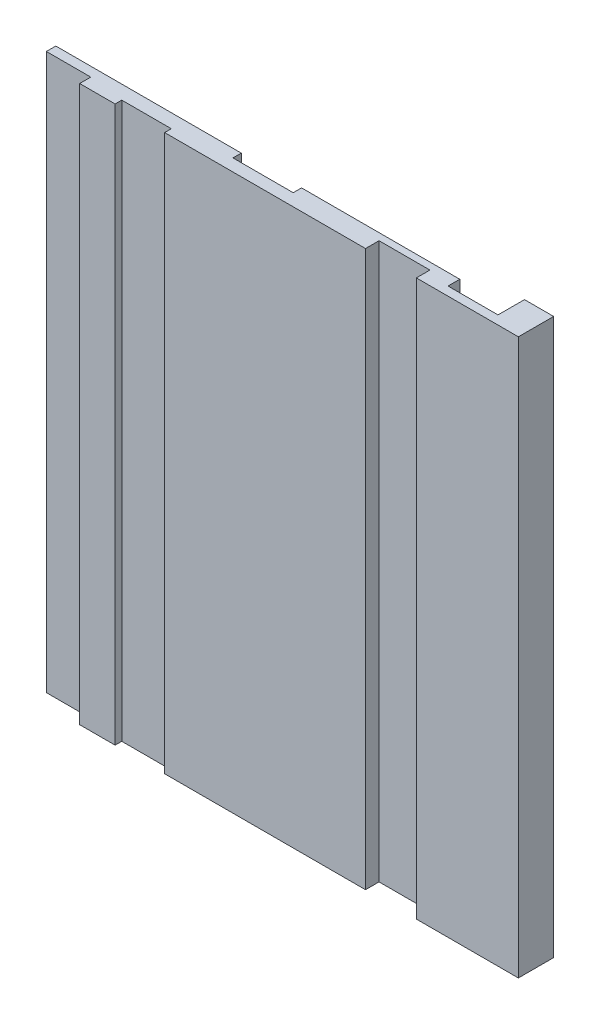
from build123d import *

# Parameters (mm, degrees)
BOSS_EXTRUDE1_DEPTH = 100


with BuildPart() as part:
    # Sketch1 → Boss-Extrude1 (new body)
    with BuildSketch(Plane(origin=(0, 0, 0), x_dir=(1, 0, 0), z_dir=(0, 1, 0))):
        Polygon((-87, 3.7), (-53.6, 3.7), (-53.6, 2.2), (-42.75, 2.2), (-42.75, 3.7), (-14.25, 3.7), (-14.25, 1.58), (-5.25, 1.58), (-5.25, 3.7), (-5.25, 6.35), (0, 6.35), (0, 0), (-18.37, 0), (-18.37, 2.44), (-27.53, 2.44), (-27.53, 0), (-63.7, 0), (-63.7, 1.2), (-72.62, 1.2), (-72.62, 0), (-79, 0), (-79, 2), (-87, 2), align=None)
    extrude(amount=BOSS_EXTRUDE1_DEPTH)


solid = part.part
